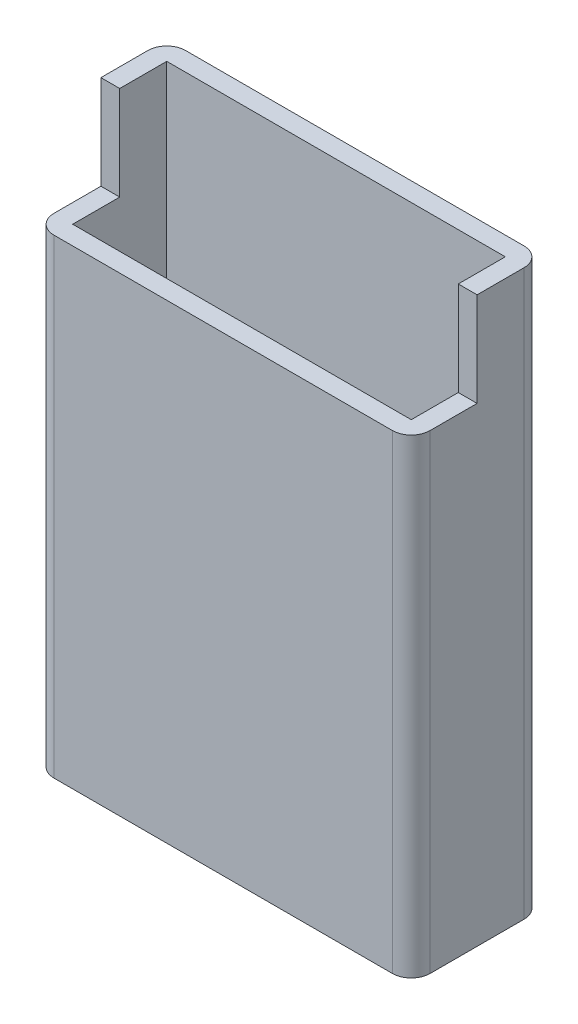
from build123d import *

# Parameters (mm, degrees)
SKETCH_1_W          = 40
SKETCH_1_H          = 14
EXTRUDE_1_DEPTH     = 60
SKETCH_6_W          = 36
SKETCH_6_H          = 10
CUT_EXTRUDE_2_DEPTH = 55
SKETCH_7_W          = 40
SKETCH_7_H          = 10
CUT_EXTRUDE_3_DEPTH = 7
SKETCH_15_OUTSIDE_W = 56.692
SKETCH_15_OUTSIDE_H = 30.692
CUT_EXTRUDE_5_DEPTH = 61


with BuildPart() as part:
    # 草图1 → 凸台-拉伸1 (new body)
    with BuildSketch(Plane(origin=(0, 0, 0), x_dir=(1, 0, 0), z_dir=(0, 1, 0))):
        with Locations((20, 7)):
            Rectangle(SKETCH_1_W, SKETCH_1_H)
    extrude(amount=EXTRUDE_1_DEPTH)

    # 草图6 → 切除-拉伸2 (cut)
    with BuildSketch(Plane(origin=(0, 60, 0), x_dir=(1, 0, 0), z_dir=(0, 1, 0))):
        with Locations((20, 7)):
            Rectangle(SKETCH_6_W, SKETCH_6_H)
    extrude(amount=-CUT_EXTRUDE_2_DEPTH, mode=Mode.SUBTRACT)

    # 草图7 → 切除-拉伸3 (cut)
    with BuildSketch(Plane.XY):
        with Locations((20, 55)):
            Rectangle(SKETCH_7_W, SKETCH_7_H)
    extrude(amount=-CUT_EXTRUDE_3_DEPTH, mode=Mode.SUBTRACT)

    # 草图15 outside → 切除-拉伸5 (cut, through all)
    with BuildSketch(Plane.XZ):
        with Locations((20, -7)):
            Rectangle(SKETCH_15_OUTSIDE_W, SKETCH_15_OUTSIDE_H)
        with BuildLine():
            Line((2, -14), (38, -14))
            ThreePointArc((38, -14), (39.414213562, -13.414213562), (40, -12))
            Line((40, -12), (40, -2))
            ThreePointArc((40, -2), (39.414213562, -0.585786438), (38, 0))
            Line((38, 0), (2, 0))
            ThreePointArc((2, 0), (0.585786438, -0.585786438), (0, -2))
            Line((0, -2), (0, -12))
            ThreePointArc((0, -12), (0.585786438, -13.414213562), (2, -14))
        make_face(mode=Mode.SUBTRACT)
    extrude(amount=-CUT_EXTRUDE_5_DEPTH, mode=Mode.SUBTRACT)


solid = part.part
